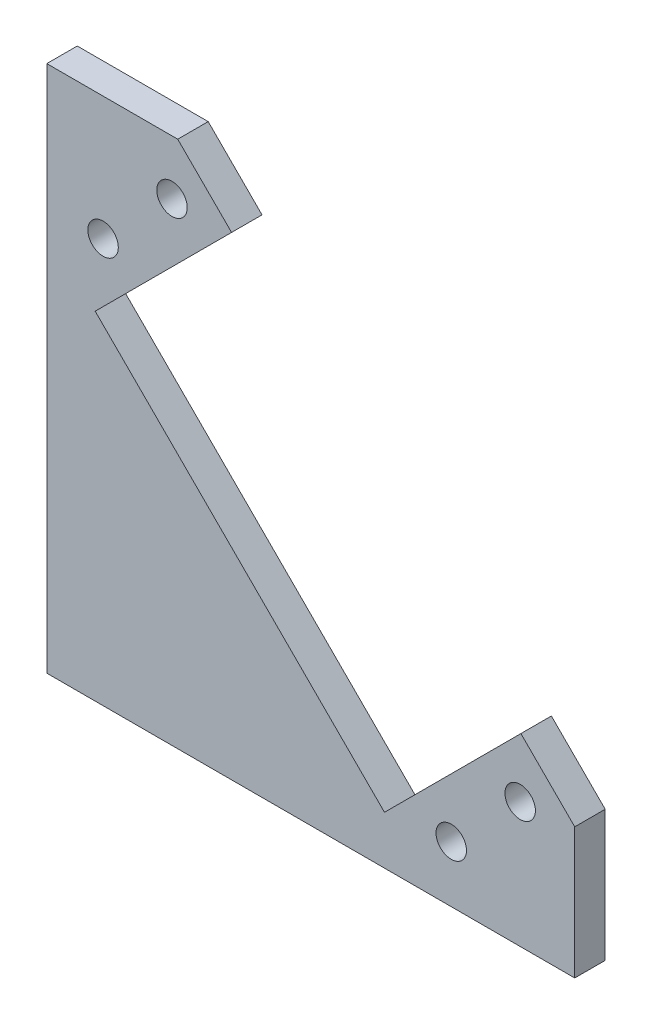
from build123d import *

# Parameters (mm, degrees)
MODEL_R                 = 1.5
SALIENTE_EXTRUIR2_DEPTH = 3


with BuildPart() as part:
    # Model → Saliente-Extruir2 (new body)
    with BuildSketch(Plane.XY):
        Polygon((18.200296, 46.696699), (4.765267, 33.26167), (33.26167, 4.765267), (46.696699, 18.200296), (52, 12.896995), (52, 0), (0, 0), (0, 52), (12.896995, 52), align=None)
        with Locations((39.837763, 5.543084)):
            Circle(MODEL_R, mode=Mode.SUBTRACT)
        with Locations((46.625988, 12.33131)):
            Circle(MODEL_R, mode=Mode.SUBTRACT)
        with Locations((12.33131, 46.625988)):
            Circle(MODEL_R, mode=Mode.SUBTRACT)
        with Locations((5.543084, 39.837763)):
            Circle(MODEL_R, mode=Mode.SUBTRACT)
    extrude(amount=SALIENTE_EXTRUIR2_DEPTH)


solid = part.part
